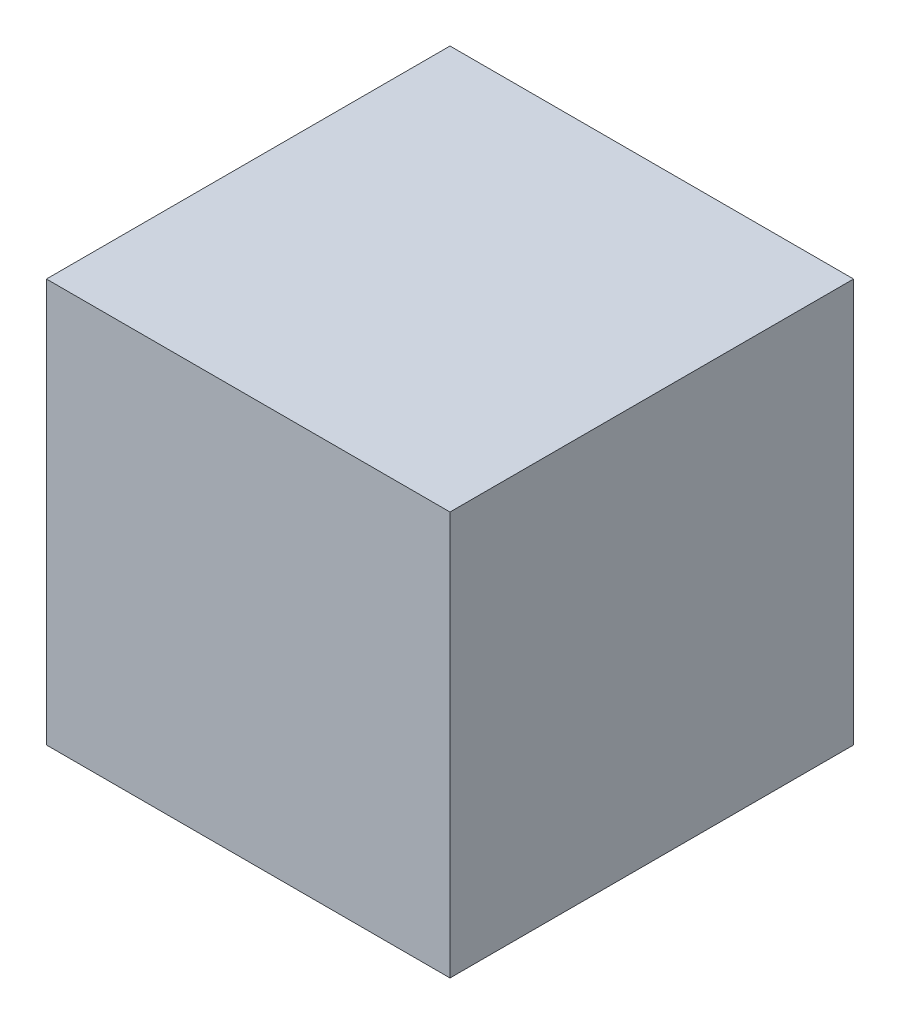
from build123d import *

# Parameters (mm, degrees)
SZKIC1_W                    = 100
SZKIC1_H                    = 100
DODANIE_WYCI_GNI_CIE1_DEPTH = 100
SKORUPA2_T                  = 10


with BuildPart() as part:
    # Szkic1 → Dodanie-wyciągnięcie1 (new body)
    with BuildSketch(Plane.XY):
        Rectangle(SZKIC1_W, SZKIC1_H)
    extrude(amount=DODANIE_WYCI_GNI_CIE1_DEPTH)

    # Skorupa2 (no face opened: a closed hollow body)
    add(offset(amount=-SKORUPA2_T, mode=Mode.PRIVATE), mode=Mode.SUBTRACT)


solid = part.part
